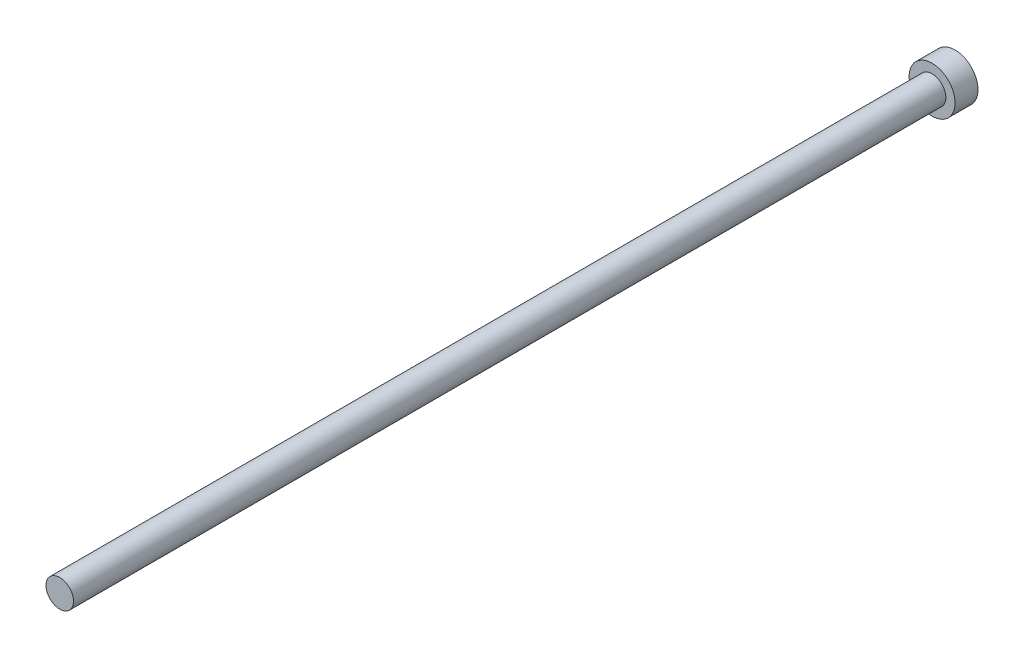
from build123d import *

# Parameters (mm, degrees)
SKETCH2_R           = 5
BOSS_EXTRUDE2_DEPTH = 5
CUT_EXTRUDE2_DEPTH  = 3
SKETCH6_R           = 3
BOSS_EXTRUDE3_DEPTH = 190


with BuildPart() as part:
    # Sketch2 → Boss-Extrude2 (new body)
    with BuildSketch(Plane.XY):
        Circle(SKETCH2_R)
    extrude(amount=BOSS_EXTRUDE2_DEPTH)

    # Sketch5 → Cut-Extrude2 (cut)
    with BuildSketch(Plane(origin=(0, 0, 0), x_dir=(-1, 0, 0), z_dir=(0, 0, -1))):
        Polygon((-3.229126368, 1.898971194), (-3.259120479, -1.847019869), (-0.029994111, -3.745991063), (3.229126368, -1.898971194), (3.259120479, 1.847019869), (0.029994111, 3.745991063), align=None)
    extrude(amount=-CUT_EXTRUDE2_DEPTH, mode=Mode.SUBTRACT)

    # Sketch6 → Boss-Extrude3 (add)
    with BuildSketch(Plane.XY.offset(5)):
        Circle(SKETCH6_R)
    extrude(amount=BOSS_EXTRUDE3_DEPTH)


solid = part.part
